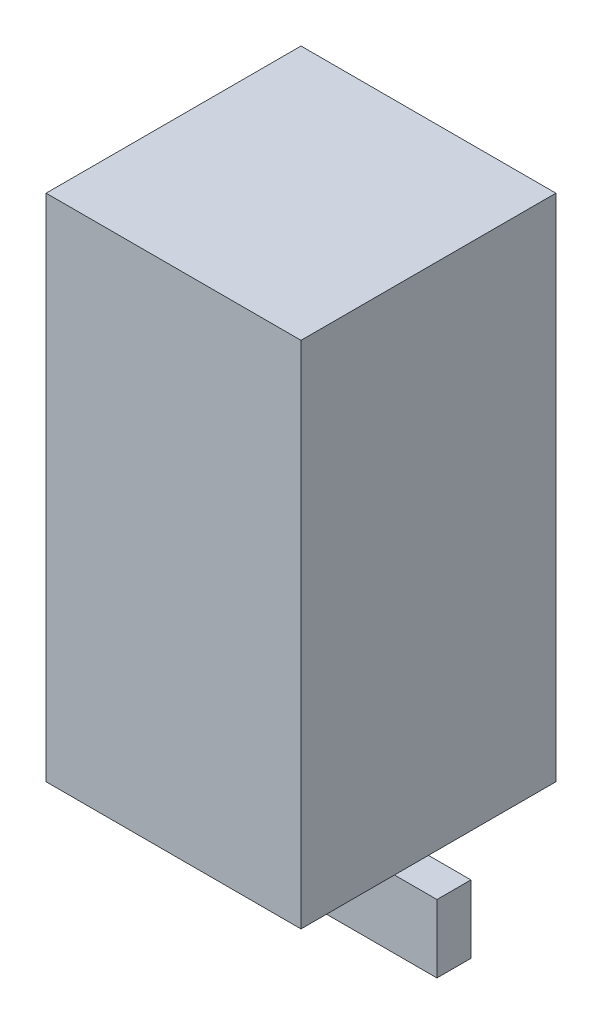
from build123d import *

# Parameters (mm, degrees)
SKETCH1_W                = 30
SKETCH1_H                = 30
BOSS_EXTRUDE1_DEPTH      = 60
SKETCH2_R                = 5
BOSS_EXTRUDE2_DEPTH      = 2
BOSS_EXTRUDE3_DEPTH      = 2
BOSS_EXTRUDE3_DEPTH_BACK = 2


with BuildPart() as part:
    # Sketch1 → Boss-Extrude1 (new body)
    with BuildSketch(Plane(origin=(0, 0, 0), x_dir=(1, 0, 0), z_dir=(0, 1, 0))):
        Rectangle(SKETCH1_W, SKETCH1_H)
    extrude(amount=BOSS_EXTRUDE1_DEPTH)

    # Sketch2 → Boss-Extrude2 (add)
    with BuildSketch(Plane.XZ):
        Circle(SKETCH2_R)
    extrude(amount=BOSS_EXTRUDE2_DEPTH)

    # Sketch4 → Boss-Extrude3 (add, two sides)
    with BuildSketch(Plane.XY) as boss_extrude3_sk:
        Polygon((-5, -2), (18, -2), (18, -10), (0.601660306, -10), align=None)
    extrude(amount=BOSS_EXTRUDE3_DEPTH)
    extrude(boss_extrude3_sk.sketch, amount=-BOSS_EXTRUDE3_DEPTH_BACK)


solid = part.part
